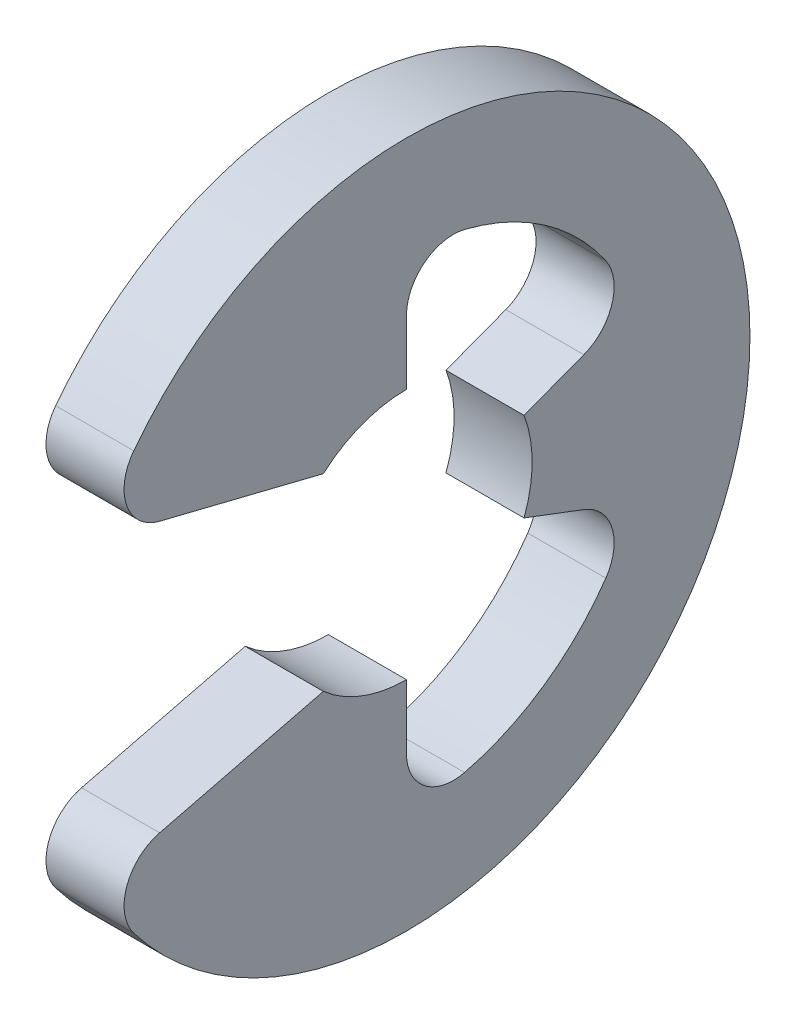
from build123d import *

# Parameters (mm, degrees)
EXTRUDE1_DEPTH = 0.25
FILLET1_R      = 0.3


with BuildPart() as part:
    # Sketch1 → Extrude1 (new body, symmetric)
    with BuildSketch(Plane(origin=(0, 0, 0), x_dir=(0, 0, -1), z_dir=(1, 0, 0))):
        with BuildLine():
            Line((-1.978193251, -0.962679314), (-0.532457451, -0.60375))
            ThreePointArc((-0.532457451, -0.60375), (-0.284610479, -0.753008549), (0, -0.805))
            Line((0, -0.805), (0, -1.550967742))
            ThreePointArc((0, -1.550967742), (0.881767522, -1.275925928), (1.450797477, -0.548349904))
            Line((1.450797477, -0.548349904), (0.753008549, -0.284610479))
            ThreePointArc((0.753008549, -0.284610479), (0.805, 0), (0.753008549, 0.284610479))
            Line((0.753008549, 0.284610479), (1.450797477, 0.548349904))
            ThreePointArc((1.450797477, 0.548349904), (0.881767522, 1.275925928), (0, 1.550967742))
            Line((0, 1.550967742), (0, 0.805))
            ThreePointArc((0, 0.805), (-0.284610479, 0.753008549), (-0.532457451, 0.60375))
            Line((-0.532457451, 0.60375), (-1.978193251, 0.962679314))
            ThreePointArc((-1.978193251, 0.962679314), (2.2, 0), (-1.978193251, -0.962679314))
        make_face()
    extrude(amount=EXTRUDE1_DEPTH, both=True)

    # Fillet1
    fillet1_edges = [part.edges().sort_by_distance(p)[0] for p in [
        (0, -0.962679314, 1.978193251),
        (0, -1.550967742, 0),
        (0, -0.548349904, -1.450797477),
        (0, 0.548349904, -1.450797477),
        (0, 1.550967742, 0),
        (0, 0.962679314, 1.978193251),
    ]]
    fillet(fillet1_edges, radius=FILLET1_R)


solid = part.part
